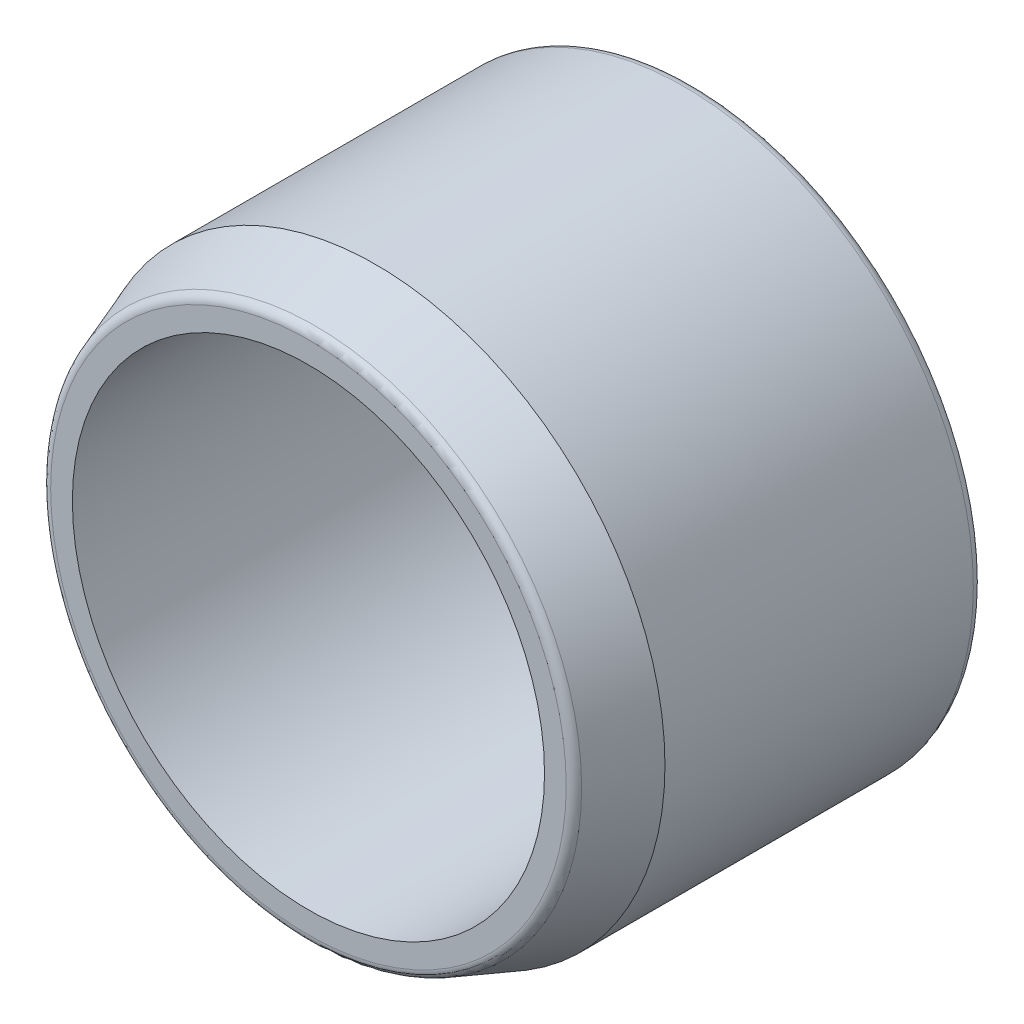
from build123d import *

# Parameters (mm, degrees)
SKETCH1_R           = 30
SKETCH1_R_2         = 24.5
BOSS_EXTRUDE1_DEPTH = 40
CHAMFER1_SIZE       = 7
CHAMFER1_SIZE2      = 2.54779164
FILLET1_R           = 1


with BuildPart() as part:
    # Sketch1 → Boss-Extrude1 (new body)
    with BuildSketch(Plane.XY):
        Circle(SKETCH1_R)
        Circle(SKETCH1_R_2, mode=Mode.SUBTRACT)
    extrude(amount=BOSS_EXTRUDE1_DEPTH)

    # Chamfer1
    chamfer1_edges = [part.edges().sort_by_distance(p)[0] for p in [
        (-30, 0, 40),
    ]]
    chamfer1_side = [part.faces().sort_by_distance(p)[0] for p in [
        (-30, 0, 20),
    ]]
    chamfer(chamfer1_edges, length=CHAMFER1_SIZE, length2=CHAMFER1_SIZE2, reference=chamfer1_side[0])

    # Fillet1
    fillet1_edges = [part.edges().sort_by_distance(p)[0] for p in [
        (-30, 0, 0),
        (-27.45220836, 0, 40),
    ]]
    fillet(fillet1_edges, radius=FILLET1_R)


solid = part.part
